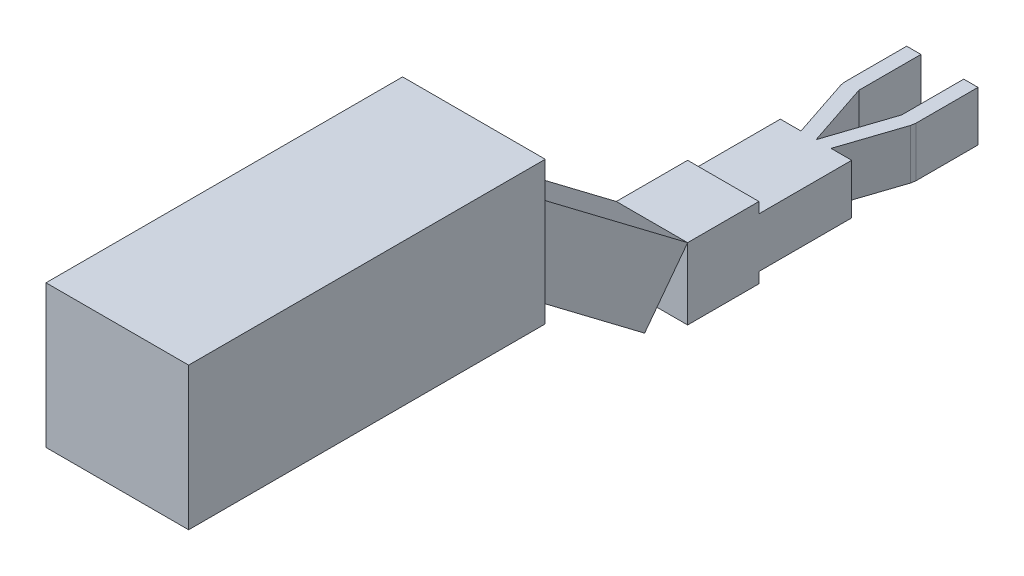
from build123d import *

# Parameters (mm, degrees)
BOSS_EXTRUDE1_DEPTH = 70
SKETCH2_W           = 100
SKETCH2_H           = 100
BOSS_EXTRUDE2_DEPTH = 100
BOSS_EXTRUDE3_DEPTH = 100
SKETCH4_W           = 500
SKETCH4_H           = 200
BOSS_EXTRUDE4_DEPTH = 200


with BuildPart() as part:
    # Sketch1 → Boss-Extrude1 (new body)
    with BuildSketch(Plane(origin=(0, 0, 0), x_dir=(1, 0, 0), z_dir=(0, 1, 0))):
        Polygon((0, -105.768782521), (-30, -15.630000635), (-30, 71.369999365), (-50, 71.369999365), (-50, -15.630000635), (-48.97658566, -21.945790108), (-21.078607457, -105.768782521), (-50, -105.768782521), (-50, -235.768782521), (50, -235.768782521), (50, -105.768782521), (21.078607457, -105.768782521), (48.97658566, -21.945790108), (50, -15.630000635), (50, 71.369999365), (30, 71.369999365), (30, -15.630000635), align=None)
    extrude(amount=BOSS_EXTRUDE1_DEPTH)

    # Sketch2 → Boss-Extrude2 (add)
    with BuildSketch(Plane.XY.offset(235.768782521)):
        with Locations((0, 35)):
            Rectangle(SKETCH2_W, SKETCH2_H)
    extrude(amount=BOSS_EXTRUDE2_DEPTH)


with BuildPart() as body_2:
    # Sketch3 → Boss-Extrude3 (new body)
    with BuildSketch(Plane.ZY.offset(50)):
        Polygon((335.768782521, 85), (396.06206918, 5.220807325), (635.399647205, 186.100667301), (575.106360546, 265.879859976), align=None)
    extrude(amount=-BOSS_EXTRUDE3_DEPTH)


with BuildPart() as body_3:
    # Sketch4 → Boss-Extrude4 (new body)
    with BuildSketch(Plane.ZY.offset(50)):
        with Locations((885.399647205, 286.100667301)):
            Rectangle(SKETCH4_W, SKETCH4_H)
    extrude(amount=-BOSS_EXTRUDE4_DEPTH)


solid = Compound([part.part, body_2.part, body_3.part])
